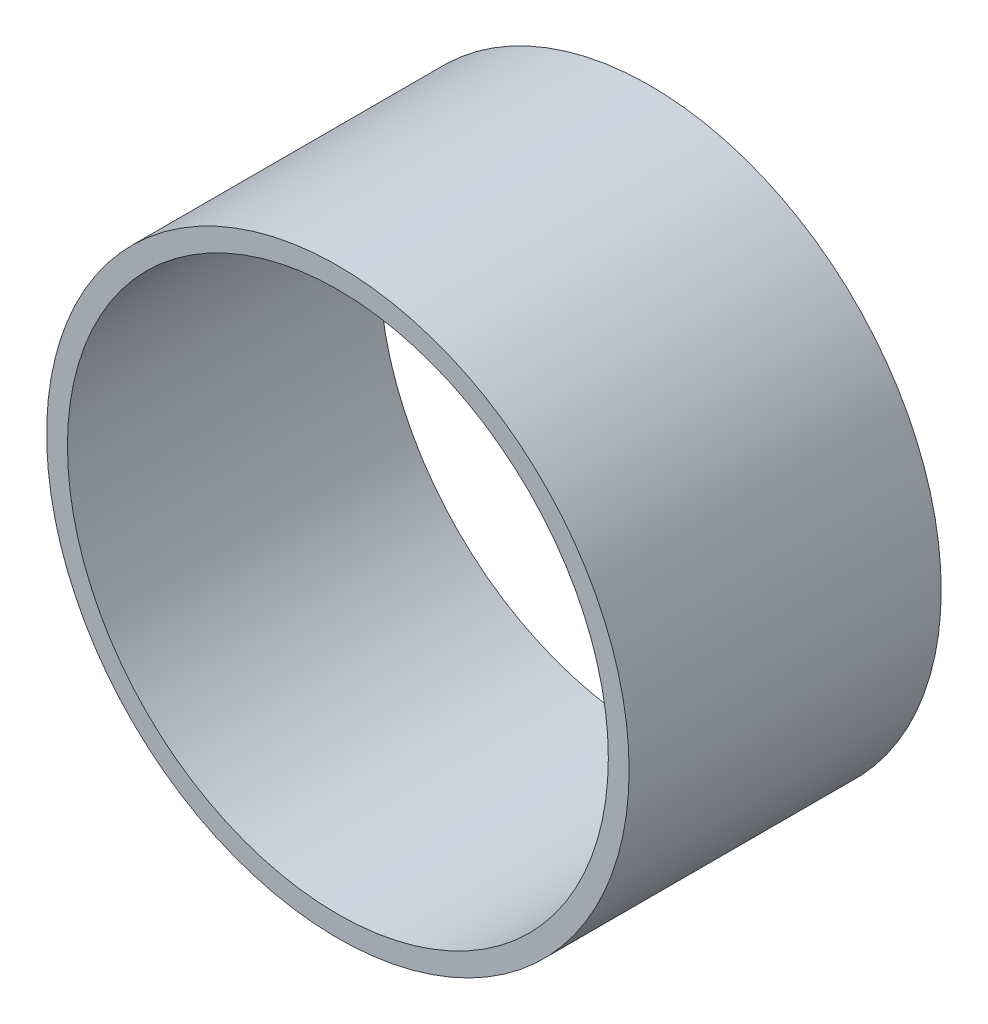
from build123d import *

# Parameters (mm, degrees)
SKETCH1_R           = 14
SKETCH1_R_2         = 13
BOSS_EXTRUDE1_DEPTH = 15


with BuildPart() as part:
    # Sketch1 → Boss-Extrude1 (new body)
    with BuildSketch(Plane.XY):
        Circle(SKETCH1_R)
        Circle(SKETCH1_R_2, mode=Mode.SUBTRACT)
    extrude(amount=BOSS_EXTRUDE1_DEPTH)


solid = part.part
